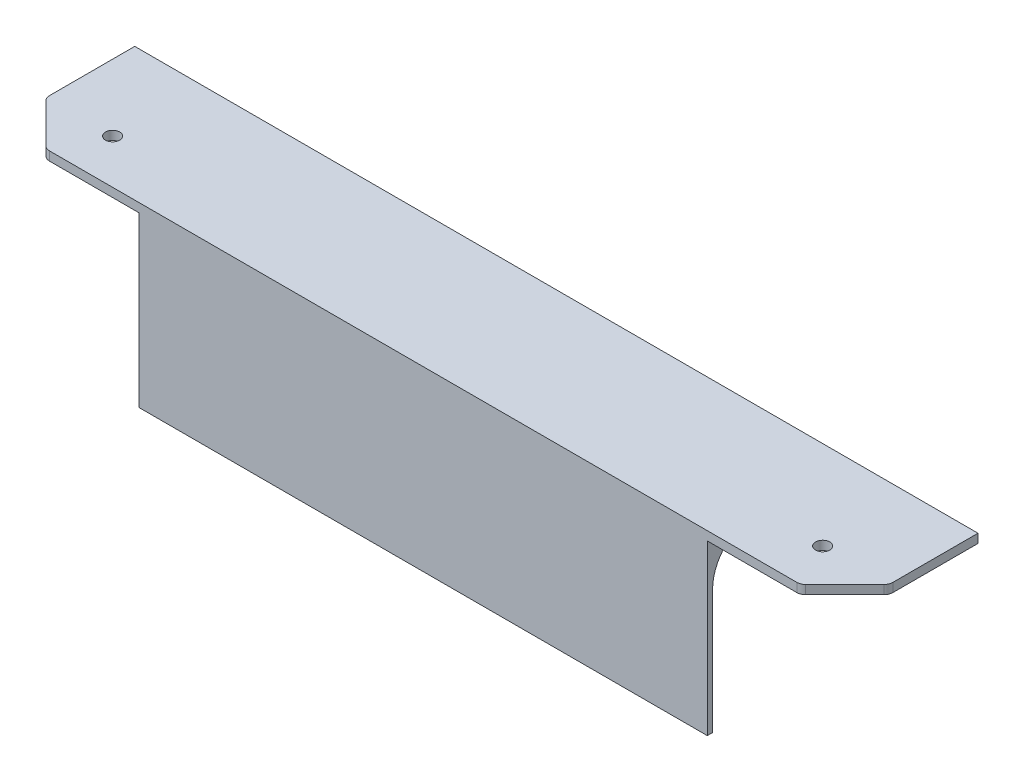
from build123d import *

# Parameters (mm, degrees)
ESQUISSE2_W             = 190
ESQUISSE2_H             = 30
BOSS_EXTRU_1_DEPTH      = 2
ESQUISSE3_W             = 128
ESQUISSE3_H             = 1.2
BOSS_EXTRU_2_DEPTH      = 38
CHANFREIN1_SIZE         = 10
CONG_1_R                = 2
ESQUISSE4_R             = 1.6
ENL_V_MAT_EXTRU_1_DEPTH = 41
CONG_2_R                = 10


with BuildPart() as part:
    # Esquisse2 → Boss.-Extru.1 (new body)
    with BuildSketch(Plane(origin=(0, 0, 0), x_dir=(1, 0, 0), z_dir=(0, 1, 0))):
        Rectangle(ESQUISSE2_W, ESQUISSE2_H)
    extrude(amount=BOSS_EXTRU_1_DEPTH)

    # Esquisse3 → Boss.-Extru.2 (add)
    with BuildSketch(Plane.XZ):
        with Locations((0, 14.4)):
            Rectangle(ESQUISSE3_W, ESQUISSE3_H)
    extrude(amount=BOSS_EXTRU_2_DEPTH)

    # Chanfrein1
    chanfrein1_edges = [part.edges().sort_by_distance(p)[0] for p in [
        (95, 1, 15),
        (-95, 1, 15),
    ]]
    chamfer(chanfrein1_edges, length=CHANFREIN1_SIZE)

    # Congé1
    cong_1_edges = [part.edges().sort_by_distance(p)[0] for p in [
        (95, 1, 5),
        (-85, 1, 15),
        (85, 1, 15),
        (-95, 1, 5),
    ]]
    fillet(cong_1_edges, radius=CONG_1_R)

    # Esquisse4 → Enlèv. mat.-Extru.1 (cut, through all)
    with BuildSketch(Plane(origin=(0, 2, 0), x_dir=(1, 0, 0), z_dir=(0, 1, 0))):
        with Locations((-80, -5)):
            Circle(ESQUISSE4_R)
        with Locations((80, -5)):
            Circle(ESQUISSE4_R)
    extrude(amount=-ENL_V_MAT_EXTRU_1_DEPTH, mode=Mode.SUBTRACT)

    # Congé2
    cong_2_edges = [part.edges().sort_by_distance(p)[0] for p in [
        (0, 0, 13.8),
    ]]
    fillet(cong_2_edges, radius=CONG_2_R)


solid = part.part
